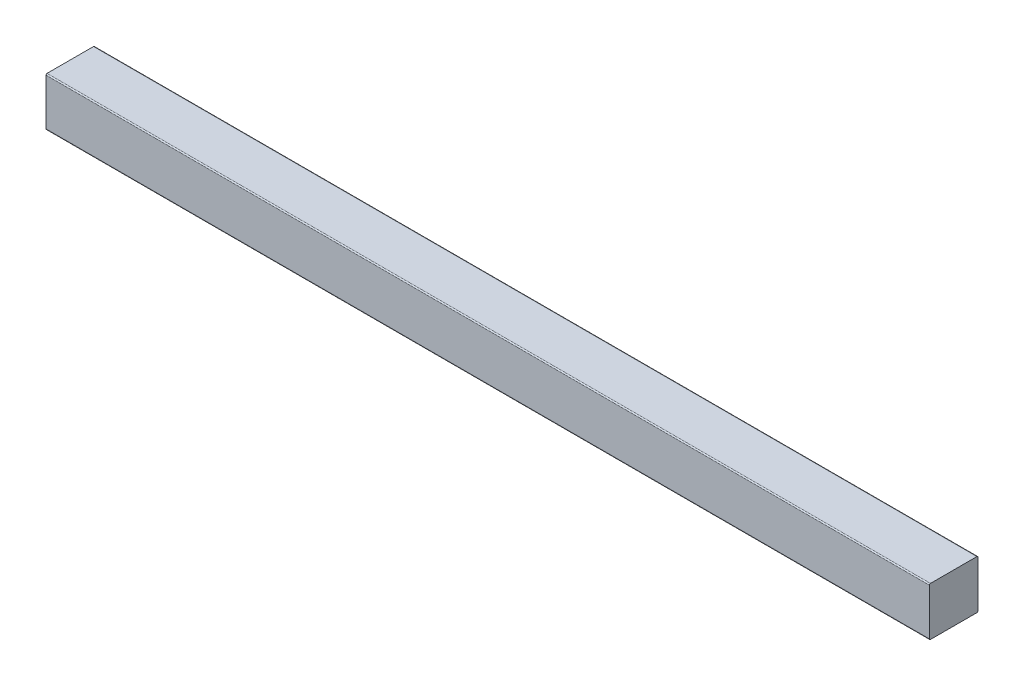
from build123d import *

# Parameters (mm, degrees)
SKETCH1_W           = 44
SKETCH1_H           = 44
BOSS_EXTRUDE1_DEPTH = 800
FILLET1_R           = 1


with BuildPart() as part:
    # Sketch1 → Boss-Extrude1 (new body)
    with BuildSketch(Plane(origin=(0, 0, 0), x_dir=(0, 0, -1), z_dir=(1, 0, 0))):
        with Locations((22, 22)):
            Rectangle(SKETCH1_W, SKETCH1_H)
    extrude(amount=BOSS_EXTRUDE1_DEPTH)

    # Fillet1
    fillet1_edges = [part.edges().sort_by_distance(p)[0] for p in [
        (400, 44, 0),
        (400, 44, -44),
        (400, 0, -44),
        (400, 0, 0),
    ]]
    fillet(fillet1_edges, radius=FILLET1_R)


solid = part.part
